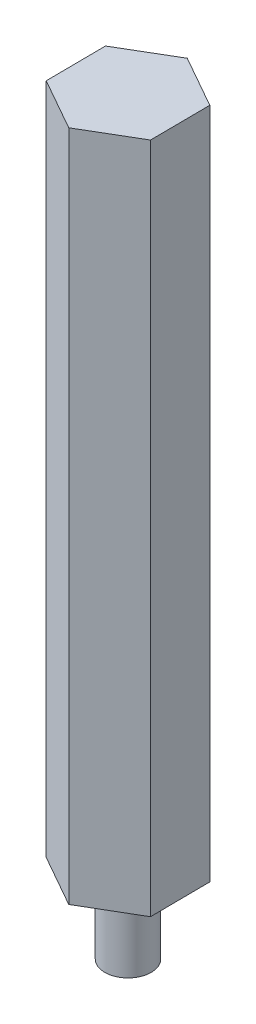
from build123d import *

# Parameters (mm, degrees)
BOSS_EXTRUDE1_DEPTH = 41.28
SKETCH3_R           = 1.4224
BOSS_EXTRUDE2_DEPTH = 4.75


with BuildPart() as part:
    # Sketch1 → Boss-Extrude1 (new body)
    with BuildSketch(Plane(origin=(0, 0, 0), x_dir=(1, 0, 0), z_dir=(0, 1, 0))):
        Polygon((3.189826296, -1.807163947), (3.159963035, 1.858888633), (-0.029863261, 3.66605258), (-3.189826296, 1.807163947), (-3.159963035, -1.858888633), (0.029863261, -3.66605258), align=None)
    extrude(amount=BOSS_EXTRUDE1_DEPTH)

    # Sketch3 → Boss-Extrude2 (add)
    with BuildSketch(Plane(origin=(0, 0, 0), x_dir=(-1, 0, 0), z_dir=(0, -1, 0))):
        Circle(SKETCH3_R)
    extrude(amount=BOSS_EXTRUDE2_DEPTH)


solid = part.part
